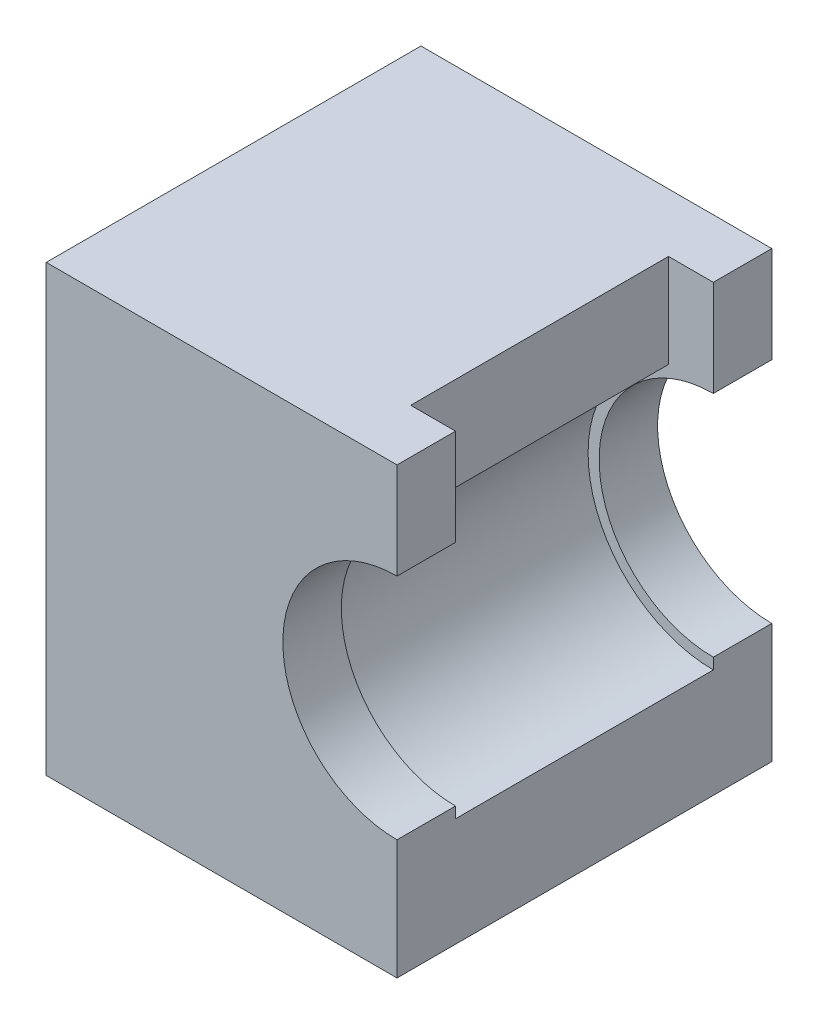
from build123d import *

# Parameters (mm, degrees)
SKETCH1_W           = 3.175
SKETCH1_H           = 9.525
SKETCH1_W_2         = 8.308704394
SKETCH1_H_2         = 2.54
BOSS_EXTRUDE1_DEPTH = 7
BOSS_EXTRUDE2_DEPTH = 1.5875


with BuildPart() as part:
    # Sketch1 → Boss-Extrude1 (new body)
    with BuildSketch(Plane.XY):
        with BuildLine():
            ThreePointArc((0, -3.4), (-3.343276836, -0.618465844), (-1.216295606, 3.175))
            Line((-1.216295606, 3.175), (-6.35, 3.175))
            Line((-6.35, 3.175), (-6.35, -6.35))
            Line((-6.35, -6.35), (0, -6.35))
            Line((0, -6.35), (0, -3.4))
        make_face()
        with Locations((-7.9375, -1.5875)):
            Rectangle(SKETCH1_W, SKETCH1_H)
        with Locations((-5.370647803, 4.445)):
            Rectangle(SKETCH1_W_2, SKETCH1_H_2)
    extrude(amount=BOSS_EXTRUDE1_DEPTH)

    # Sketch2 → Boss-Extrude2 (add)
    with BuildSketch(Plane.XY.offset(7)):
        with BuildLine():
            Line((-1.216295606, 3.175), (-1.216295606, 5.715))
            Line((-1.216295606, 5.715), (-9.525, 5.715))
            Line((-9.525, 5.715), (-9.525, -6.35))
            Line((-9.525, -6.35), (-1.216295606, -6.35))
            Line((-1.216295606, -6.35), (-1.216295606, -3.175))
            ThreePointArc((-1.216295606, -3.175), (-3.4, 0), (-1.216295606, 3.175))
        make_face()
        with BuildLine():
            Line((-1.216295606, 2.851425082), (-1.216295606, 3.175))
            ThreePointArc((-1.216295606, 3.175), (-3.4, 0), (-1.216295606, -3.175))
            Line((-1.216295606, -3.175), (-1.216295606, -2.851425082))
            ThreePointArc((-1.216295606, -2.851425082), (-3.1, 0), (-1.216295606, 2.851425082))
        make_face()
        with BuildLine():
            Line((-1.216295606, -2.851425082), (-1.216295606, -3.175))
            ThreePointArc((-1.216295606, -3.175), (-0.618465844, -3.343276836), (0, -3.4))
            Line((0, -3.4), (0, -3.1))
            ThreePointArc((0, -3.1), (-0.620718231, -3.037220584), (-1.216295606, -2.851425082))
        make_face()
        with BuildLine():
            ThreePointArc((0, -3.4), (-0.618465844, -3.343276836), (-1.216295606, -3.175))
            Line((-1.216295606, -3.175), (-1.216295606, -6.35))
            Line((-1.216295606, -6.35), (0, -6.35))
            Line((0, -6.35), (0, -3.4))
        make_face()
        with BuildLine():
            Line((0, 5.715), (-1.216295606, 5.715))
            Line((-1.216295606, 5.715), (-1.216295606, 3.175))
            Line((-1.216295606, 3.175), (-1.216295606, 2.851425082))
            ThreePointArc((-1.216295606, 2.851425082), (-0.620718231, 3.037220584), (0, 3.1))
            Line((0, 3.1), (0, 5.715))
        make_face()
    boss_extrude2 = extrude(amount=BOSS_EXTRUDE2_DEPTH)

    # Mirror1: Boss-Extrude2 across plane
    add(boss_extrude2.mirror(Plane.XY.offset(3.5)))


solid = part.part
